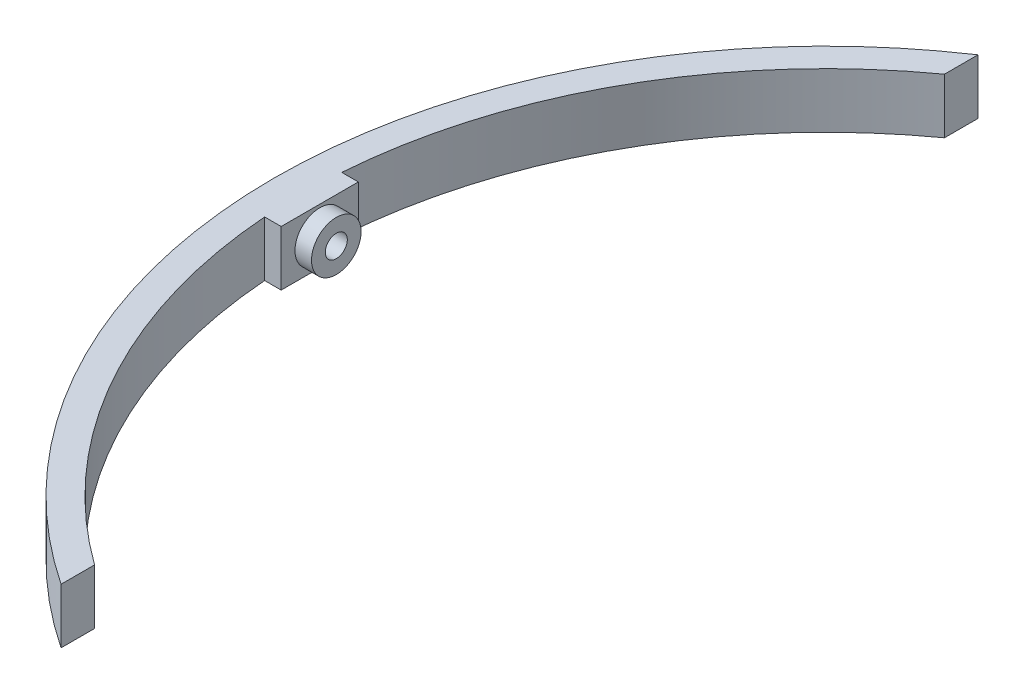
from build123d import *

# Parameters (mm, degrees)
BOSS_EXTRUDE1_DEPTH = 10
SKETCH2_R           = 4.5
SKETCH2_R_2         = 2
BOSS_EXTRUDE2_DEPTH = 3
SKETCH3_R           = 2
CUT_EXTRUDE1_DEPTH  = 10


with BuildPart() as part:
    # Sketch1 → Boss-Extrude1 (new body)
    with BuildSketch(Plane(origin=(0, 0, 0), x_dir=(1, 0, 0), z_dir=(0, 1, 0))):
        with BuildLine():
            Line((-55.497854759, 77.103749047), (-55.497854759, 83.186465949))
            ThreePointArc((-55.497854759, 83.186465949), (-100, 0), (-55.497854759, -83.186465949))
            Line((-55.497854759, -83.186465949), (-55.497854759, -77.103749047))
            ThreePointArc((-55.497854759, -77.103749047), (-95, 0), (-55.497854759, 77.103749047))
        make_face()
        with BuildLine():
            ThreePointArc((-94.742105263, 6.995247694), (-94.99999988, -0.004765259), (-94.741403014, -7.004752306))
            Line((-94.741403014, -7.004752306), (-91.742105263, -7.004752306))
            Line((-91.742105263, -7.004752306), (-91.742105263, 6.995247694))
            Line((-91.742105263, 6.995247694), (-94.037988578, 6.995247694))
            Line((-94.037988578, 6.995247694), (-94.742105263, 6.995247694))
        make_face()
    extrude(amount=BOSS_EXTRUDE1_DEPTH)

    # Sketch2 → Boss-Extrude2 (add)
    with BuildSketch(Plane(origin=(-91.742105263, 0, 0), x_dir=(0, 0, -1), z_dir=(1, 0, 0))):
        with Locations((0, 4.938431858)):
            Circle(SKETCH2_R)
        with Locations((0, 4.938431858)):
            Circle(SKETCH2_R_2, mode=Mode.SUBTRACT)
    extrude(amount=BOSS_EXTRUDE2_DEPTH)

    # Sketch3 → Cut-Extrude1 (cut)
    with BuildSketch(Plane(origin=(-91.742105263, 0, 0), x_dir=(0, 0, -1), z_dir=(1, 0, 0))):
        with Locations((0, 4.938431858)):
            Circle(SKETCH3_R)
    extrude(amount=-CUT_EXTRUDE1_DEPTH, mode=Mode.SUBTRACT)


solid = part.part
